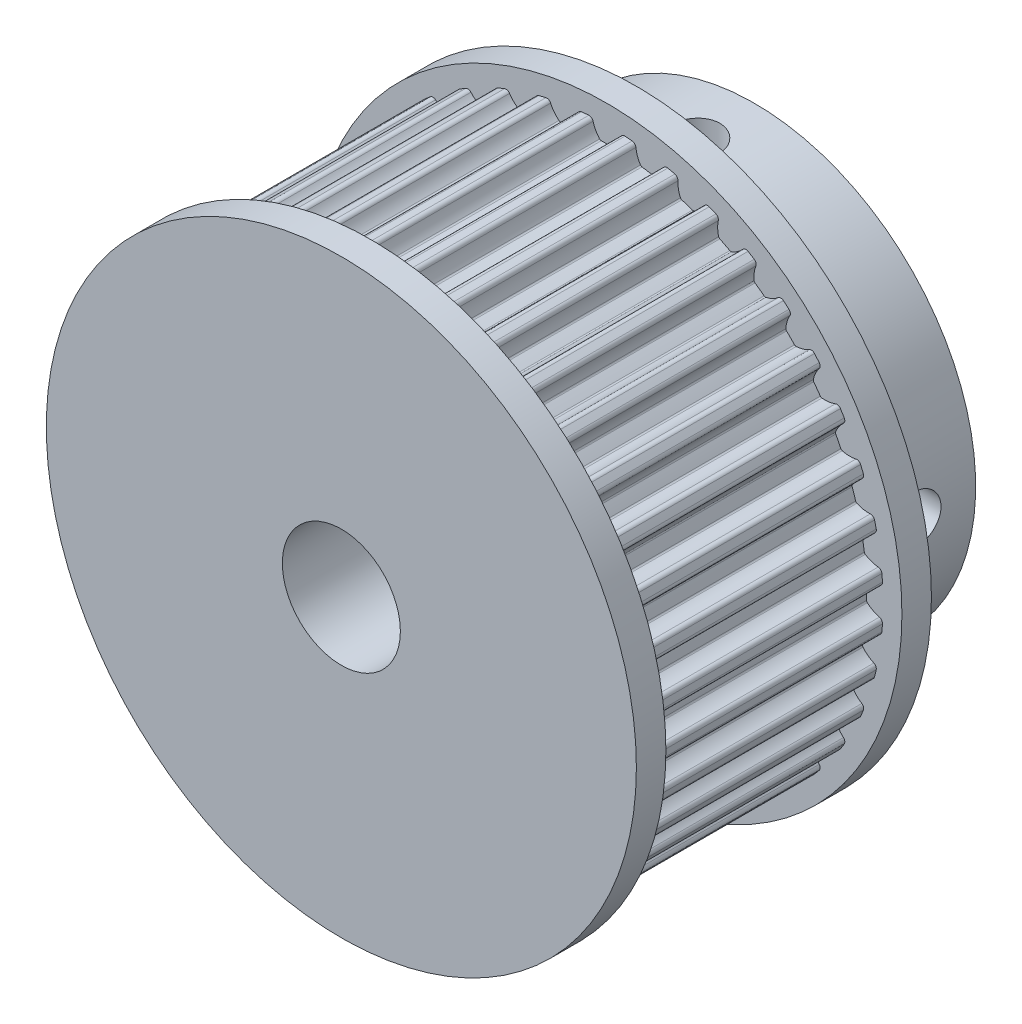
from build123d import *

# Parameters (mm, degrees)
SKETCH_1_R               = 18.72
EXTRUDE_1_DEPTH          = 8
CUT_EXTRUDE_START        = -17
CUT_EXTRUDE_1_DEPTH      = 18
PATTERN_CIRCULAR_1_COUNT = 40
SKETCH_3_R               = 20
EXTRUDE_2_DEPTH          = 2
SKETCH_5_R               = 15
EXTRUDE_3_DEPTH          = 8
SKETCH_4_R               = 4
CUT_EXTRUDE_2_DEPTH      = 29
SKETCH_7_W               = 1.65
SKETCH_7_H               = 20
PATTERN_CIRCULAR_2_COUNT = 2
PATTERN_CIRCULAR_2_ANGLE = 90


with BuildPart() as part:
    # 草圖1 → 填料-伸長1 (new body, symmetric)
    with BuildSketch(Plane.XY):
        Circle(SKETCH_1_R)
    extrude(amount=EXTRUDE_1_DEPTH, both=True)

    # 草圖2 → 除料-伸長1 (cut)
    with BuildSketch(Plane.XY.offset(8).offset(CUT_EXTRUDE_START)):
        with BuildLine():
            Line((-95.792180753, 12.482504448), (-1.22417178, 18.679930499))
            ThreePointArc((-1.22417178, 18.679930499), (-1.042236309, 18.627745125), (-0.935067184, 18.471736768))
            ThreePointArc((-0.935067184, 18.471736768), (-0.763897134, 18.03759103), (-0.495640081, 17.655727361))
            ThreePointArc((-0.495640081, 17.655727361), (-0.443624259, 17.618232135), (-0.380703112, 17.60588439))
            ThreePointArc((-0.380703112, 17.60588439), (0, 17.61), (0.380703112, 17.60588439))
            ThreePointArc((0.380703112, 17.60588439), (0.443624259, 17.618232135), (0.495640081, 17.655727361))
            ThreePointArc((0.495640081, 17.655727361), (0.763897134, 18.03759103), (0.935067184, 18.471736768))
            ThreePointArc((0.935067184, 18.471736768), (1.042236309, 18.627745125), (1.22417178, 18.679930499))
            Line((1.22417178, 18.679930499), (95.792180753, 12.482504448))
            Line((95.792180753, 12.482504448), (95.792180753, 202.024229783))
            Line((95.792180753, 202.024229783), (-95.792180753, 202.024229783))
            Line((-95.792180753, 202.024229783), (-95.792180753, 12.482504448))
        make_face()
    cut_extrude_1 = extrude(amount=CUT_EXTRUDE_1_DEPTH, mode=Mode.SUBTRACT)

    # 環狀複製排列1: 除料-伸長1 ×40 about axis
    pattern_circular_1_axis = Axis((0, 0, 8), (0, 0, 1))
    for i in range(1, PATTERN_CIRCULAR_1_COUNT):
        add(cut_extrude_1.rotate(pattern_circular_1_axis, i * 360 / PATTERN_CIRCULAR_1_COUNT), mode=Mode.SUBTRACT)

    # 草圖3 → 填料-伸長2 (add)
    with BuildSketch(Plane.XY.offset(8)):
        Circle(SKETCH_3_R)
    extrude_2 = extrude(amount=EXTRUDE_2_DEPTH)

    # 鏡射1: 填料-伸長2 across plane
    add(extrude_2.mirror(Plane.XY))

    # 草圖5 → 填料-伸長3 (add)
    with BuildSketch(Plane(origin=(0, 0, -10), x_dir=(-1, 0, 0), z_dir=(0, 0, -1))):
        Circle(SKETCH_5_R)
    extrude(amount=EXTRUDE_3_DEPTH)

    # 草圖4 → 除料-伸長2 (cut, through all)
    with BuildSketch(Plane.XY.offset(10)):
        Circle(SKETCH_4_R)
    extrude(amount=-CUT_EXTRUDE_2_DEPTH, mode=Mode.SUBTRACT)

    # 草圖7 → M4x0.7 螺紋孔1 (revolve, cut)
    with BuildSketch(Plane(origin=(0, 0, -14), x_dir=(0, 0, -1), z_dir=(1, 0, 0))):
        with Locations((0.825, 10)):
            Rectangle(SKETCH_7_W, SKETCH_7_H)
    m4x0_7_1 = revolve(axis=Axis((0, -6.35, -14), (0, 1, 0)), mode=Mode.SUBTRACT)

    # 環狀複製排列2: M4x0.7 螺紋孔1 ×2 about axis
    pattern_circular_2_axis = Axis((0, 0, -18), (0, 0, -1))
    for i in range(1, PATTERN_CIRCULAR_2_COUNT):
        add(m4x0_7_1.rotate(pattern_circular_2_axis, i * PATTERN_CIRCULAR_2_ANGLE / (PATTERN_CIRCULAR_2_COUNT - 1)), mode=Mode.SUBTRACT)


solid = part.part
